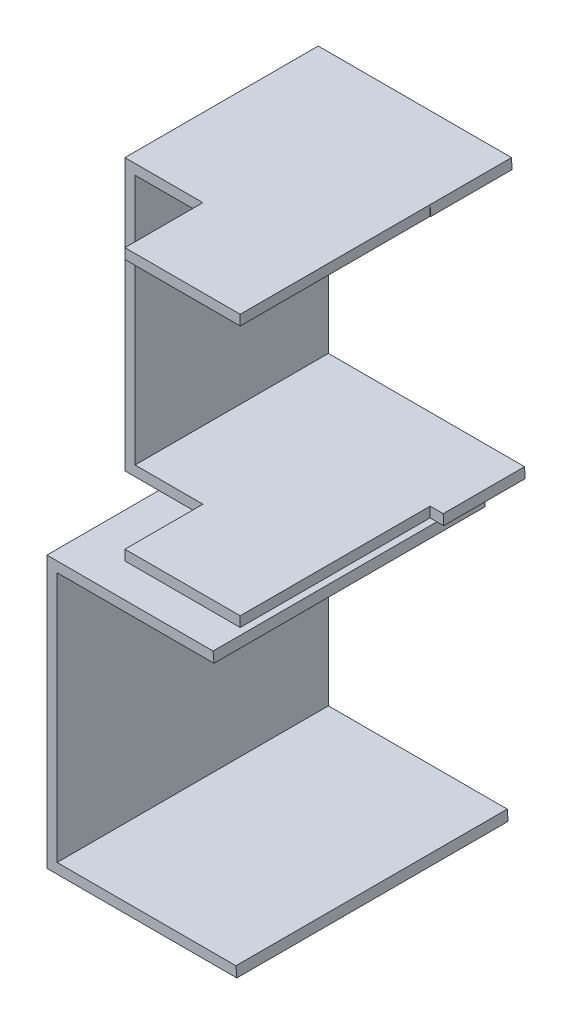
from build123d import *

# Parameters (mm, degrees)
EXTRUDE_1_DEPTH     = 80
EXTRUDE_2_DEPTH     = 80
SKETCH_4_W          = 23
SKETCH_4_H          = 23
CUT_EXTRUDE_5_DEPTH = 80
SKETCH_5_W          = 4
SKETCH_5_H          = 56
CUT_EXTRUDE_7_DEPTH = 80


with BuildPart() as part:
    # 스케치1 → 보스-돌출1 (new body)
    with BuildSketch(Plane.XY):
        Polygon((0, 0), (61, 0), (60.85, 3), (3, 3), (3, 77), (57.15, 77), (57, 80), (0, 80), align=None)
    extrude(amount=EXTRUDE_1_DEPTH)

    # 스케치4 → 컷-돌출5 (cut)
    with BuildSketch(Plane(origin=(0, 80, 0), x_dir=(1, 0, 0), z_dir=(0, 1, 0))):
        with Locations((11.5, -68.5)):
            Rectangle(SKETCH_4_W, SKETCH_4_H)
    extrude(amount=-CUT_EXTRUDE_5_DEPTH, mode=Mode.SUBTRACT)

    # 스케치5 → 컷-돌출7 (cut)
    with BuildSketch(Plane(origin=(0, 80, 0), x_dir=(1, 0, 0), z_dir=(0, 1, 0))):
        with Locations((59, -52)):
            Rectangle(SKETCH_5_W, SKETCH_5_H)
    extrude(amount=-CUT_EXTRUDE_7_DEPTH, mode=Mode.SUBTRACT)


with BuildPart() as body_2:
    # 스케치1<3> → 보스-돌출2 (new body)
    with BuildSketch(Plane.XY):
        Polygon((0, -10), (49, -10), (49.2625, -13), (3, -13), (3, -87), (55.7375, -87), (56, -90), (0, -90), align=None)
    extrude(amount=EXTRUDE_2_DEPTH)


solid = Compound([part.part, body_2.part])
